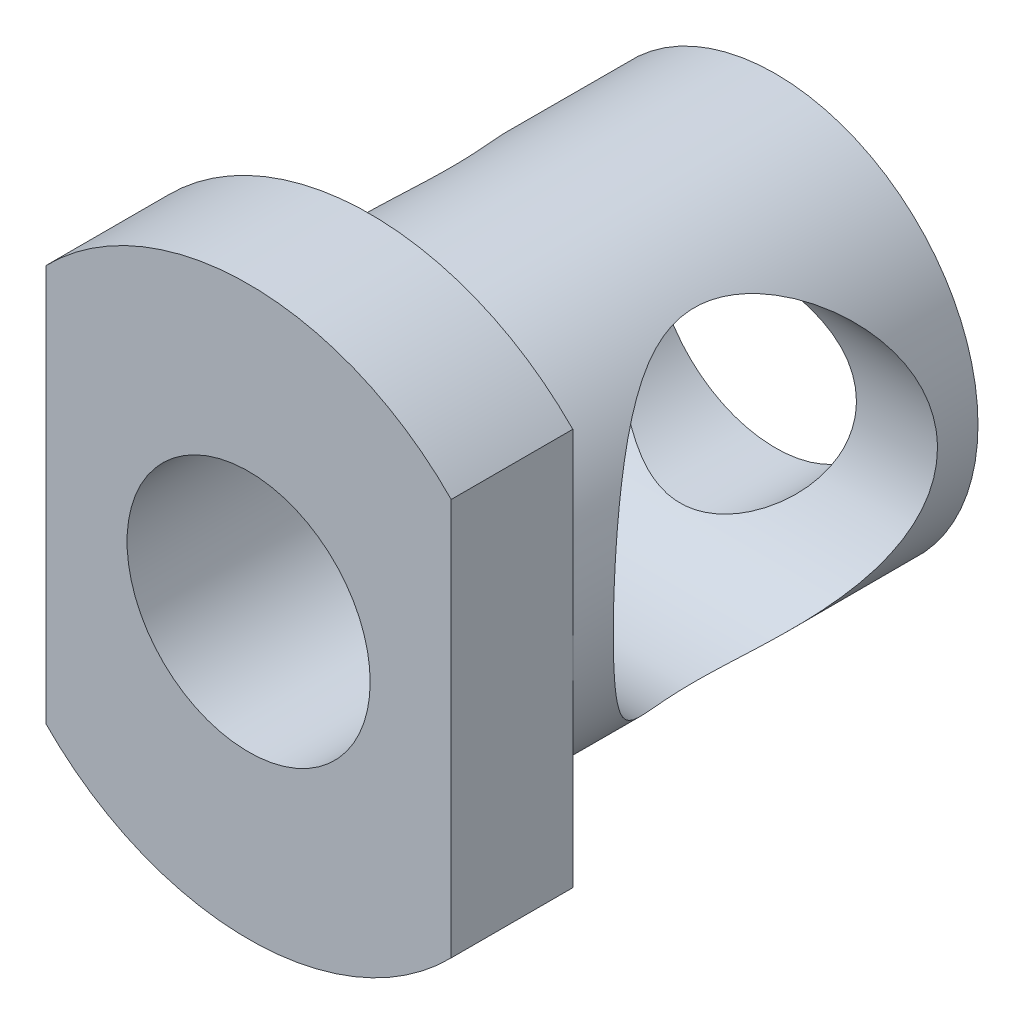
from build123d import *

# Parameters (mm, degrees)
SKETCH_1_R          = 2.5
EXTRUDE_1_DEPTH     = 5
EXTRUDE_2_DEPTH     = 1.5
SKETCH_3_R          = 1.5
CUT_EXTRUDE_1_DEPTH = 7.5
SKETCH_4_R          = 2
CUT_EXTRUDE_2_DEPTH = 5


with BuildPart() as part:
    # 草图1 → 凸台-拉伸1 (new body)
    with BuildSketch(Plane.XY):
        Circle(SKETCH_1_R)
    extrude(amount=EXTRUDE_1_DEPTH)

    # 草图2 → 凸台-拉伸2 (add)
    with BuildSketch(Plane.XY.offset(5)):
        with BuildLine():
            Line((-2.5, 2.449489743), (-2.5, -2.449489743))
            ThreePointArc((-2.5, -2.449489743), (0, -3.5), (2.5, -2.449489743))
            Line((2.5, -2.449489743), (2.5, 2.449489743))
            ThreePointArc((2.5, 2.449489743), (0, 3.5), (-2.5, 2.449489743))
        make_face()
    extrude(amount=EXTRUDE_2_DEPTH)

    # 草图3 → 切除-拉伸1 (cut, through all)
    with BuildSketch(Plane.XY.offset(6.5)):
        Circle(SKETCH_3_R)
    extrude(amount=-CUT_EXTRUDE_1_DEPTH, mode=Mode.SUBTRACT)

    # 草图4 → 切除-拉伸2 (cut, symmetric)
    with BuildSketch(Plane(origin=(0, 0, 0), x_dir=(0, 0, -1), z_dir=(1, 0, 0))):
        with Locations((-2.5, 0)):
            Circle(SKETCH_4_R)
    extrude(amount=CUT_EXTRUDE_2_DEPTH, both=True, mode=Mode.SUBTRACT)


solid = part.part
